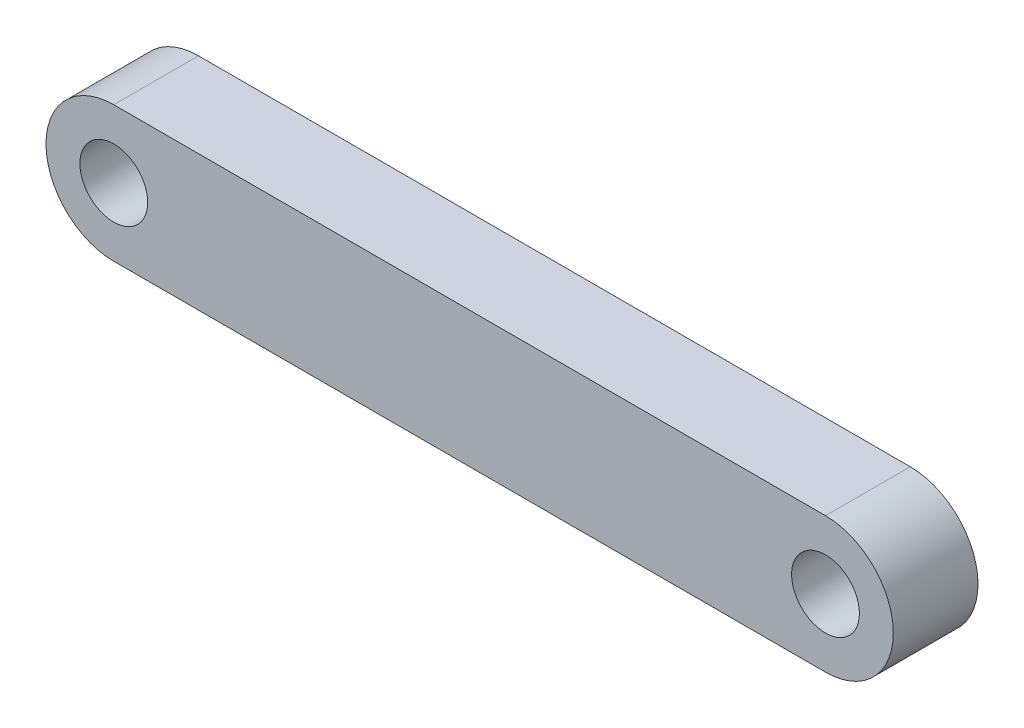
from build123d import *

# Parameters (mm, degrees)
BOSS_EXTRUDE1_DEPTH = 2.5
SKETCH2_R           = 2
CUT_EXTRUDE1_DEPTH  = 6


with BuildPart() as part:
    # Sketch1 → Boss-Extrude1 (new body, symmetric)
    with BuildSketch(Plane.XY):
        with BuildLine():
            Line((0, 4), (42, 4))
            ThreePointArc((42, 4), (46, 0), (42, -4))
            Line((42, -4), (0, -4))
            ThreePointArc((0, -4), (-4, 0), (0, 4))
        make_face()
    extrude(amount=BOSS_EXTRUDE1_DEPTH, both=True)

    # Sketch2 → Cut-Extrude1 (cut, through all)
    with BuildSketch(Plane.XY.offset(2.5)):
        with Locations((42, 0)):
            Circle(SKETCH2_R)
        Circle(SKETCH2_R)
    extrude(amount=-CUT_EXTRUDE1_DEPTH, mode=Mode.SUBTRACT)


solid = part.part
